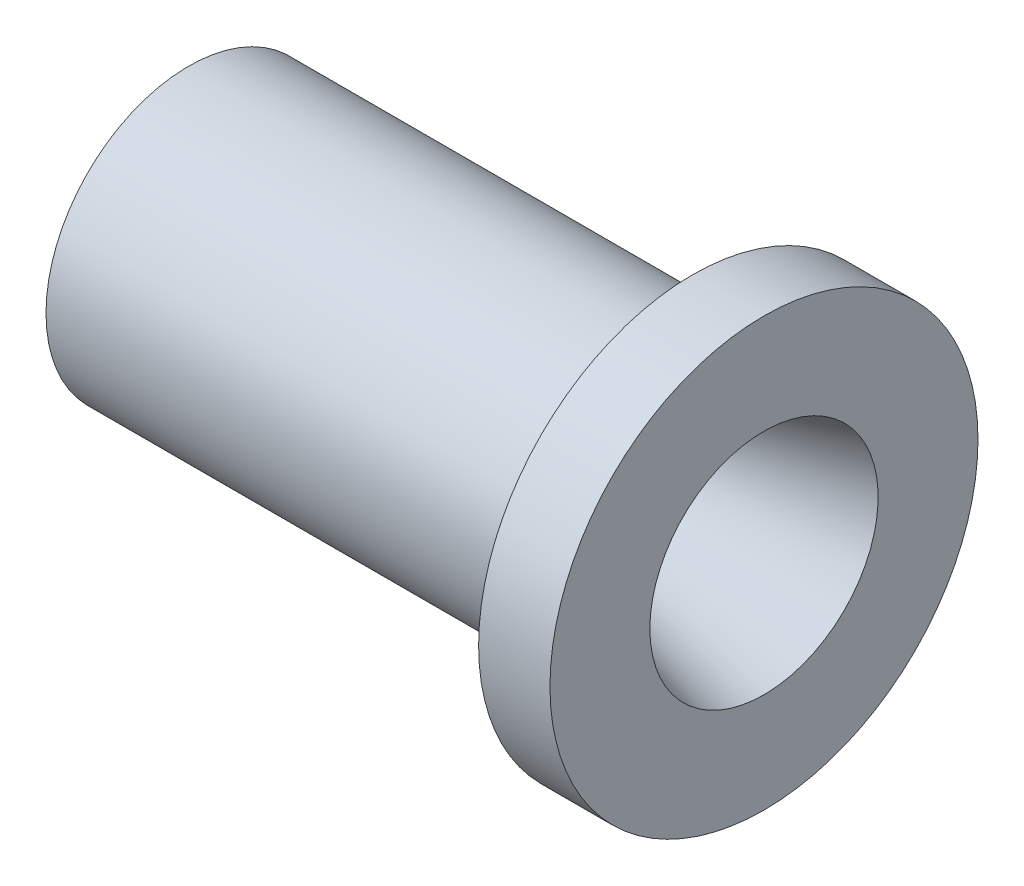
from build123d import *


with BuildPart() as part:
    # Sketch1 → Revolve1 (revolve)
    with BuildSketch(Plane.XY):
        Polygon((-16.759113577, 5.08), (-6.599113577, 5.08), (0, 1.27), (1.27, 1.27), (34.447931679, 10.16), (34.447931679, 19.05), (28.097931679, 19.05), (28.097931679, 12.7), (-16.759113577, 12.7), align=None)
    revolve(axis=Axis((0, 0, 0), (1, 0, 0)))


solid = part.part
